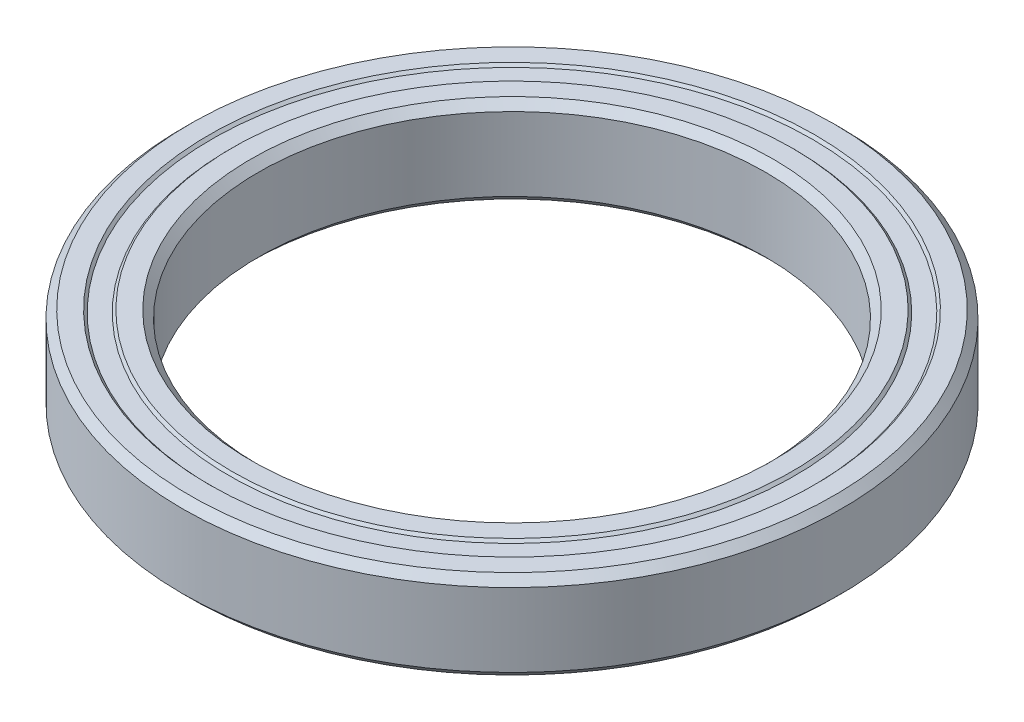
from build123d import *


with BuildPart() as part:
    # Sketch1 → Revolve1 (revolve)
    with BuildSketch(Plane.XY):
        Polygon((20, 2.9), (20, -2.9), (20.6, -3.5), (22.1, -3.5), (22.3, -3.3), (23.7, -3.3), (23.9, -3.5), (25.4, -3.5), (26, -2.9), (26, 2.9), (25.4, 3.5), (23.9, 3.5), (23.7, 3.3), (22.3, 3.3), (22.1, 3.5), (20.6, 3.5), align=None)
    revolve(axis=Axis((0, -1.349421972, 0), (0, 1, 0)))


solid = part.part
